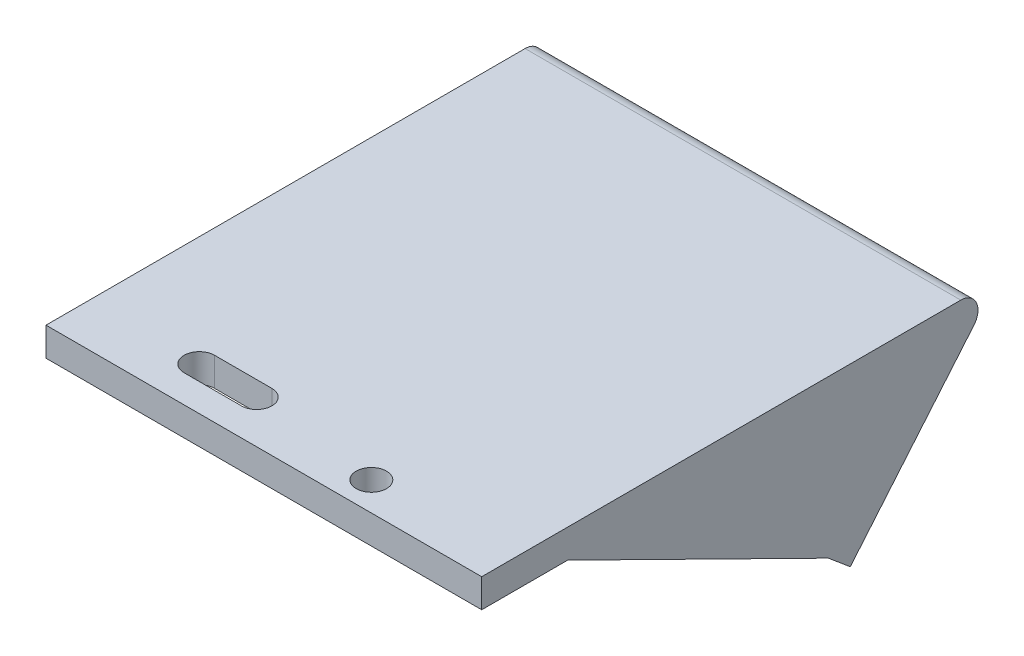
from build123d import *

# Parameters (mm, degrees)
EXTRUDE_1_DEPTH     = 70
SKETCH_2_R          = 1.65
CUT_EXTRUDE_1_DEPTH = 25.69615506
FILLET_1_R          = 3
SKETCH_6_R          = 2.65
CUT_EXTRUDE_4_DEPTH = 31.641777725
EXTRUDE_2_DEPTH     = 3
CUT_EXTRUDE_5_DEPTH = 31.641777725


with BuildPart() as part:
    # 草图1 → 凸台-拉伸1 (new body)
    with BuildSketch(Plane(origin=(0, 0, 0), x_dir=(0, 0, -1), z_dir=(1, 0, 0))):
        Polygon((0, 0), (90, 0), (64.288495613, -30.641777725), (60.458273397, -27.427839676), (79.277465397, -5), (0, -5), align=None)
    extrude(amount=EXTRUDE_1_DEPTH)

    # 草图2 → 切除-拉伸1 (cut, through all)
    with BuildSketch(Plane(origin=(0, -41.102410837, -48.983945779), x_dir=(1, 0, 0), z_dir=(0, 0.64278761, 0.766044443))):
        with Locations((12.5, 27.850884872)):
            Circle(SKETCH_2_R)
        with Locations((57.5, 27.850884872)):
            Circle(SKETCH_2_R)
    extrude(amount=-CUT_EXTRUDE_1_DEPTH, mode=Mode.SUBTRACT)

    # 圆角1
    fillet_1_edges = [part.edges().sort_by_distance(p)[0] for p in [
        (35, 0, -90),
        (35, -5, -79.277465397),
    ]]
    fillet(fillet_1_edges, radius=FILLET_1_R)

    # 草图6 → 切除-拉伸4 (cut, through all)
    with BuildSketch(Plane(origin=(0, 0, 0), x_dir=(1, 0, 0), z_dir=(0, 1, 0))):
        with Locations((48.75, 5)):
            Circle(SKETCH_6_R)
    extrude(amount=-CUT_EXTRUDE_4_DEPTH, mode=Mode.SUBTRACT)

    # 草图7 → 凸台-拉伸2 (add)
    with BuildSketch(Plane.ZY):
        with BuildLine():
            Line((-60.458273397, -27.427839676), (-15, -5))
            Line((-15, -5), (0, -5))
            Line((0, -5), (0, 0))
            Line((0, 0), (-83.566479238, 0))
            ThreePointArc((-83.566479238, 0), (-86.2854026, -1.732145215), (-85.864612568, -4.928362829))
            Line((-85.864612568, -4.928362829), (-64.288495613, -30.641777725))
            Line((-64.288495613, -30.641777725), (-60.458273397, -27.427839676))
        make_face()
    extrude_2 = extrude(amount=EXTRUDE_2_DEPTH)

    # 镜向1: 凸台-拉伸2 across plane
    add(extrude_2.mirror(Plane.ZY.offset(-35)))

    # 草图8 → 切除-拉伸5 (cut, through all)
    with BuildSketch(Plane(origin=(0, 0, 0), x_dir=(1, 0, 0), z_dir=(0, 1, 0))):
        with BuildLine():
            Line((16.25, 10.15), (26.25, 10.15))
            ThreePointArc((26.25, 10.15), (28.9, 7.5), (26.25, 4.85))
            Line((26.25, 4.85), (16.25, 4.85))
            ThreePointArc((16.25, 4.85), (13.6, 7.5), (16.25, 10.15))
        make_face()
    extrude(amount=-CUT_EXTRUDE_5_DEPTH, mode=Mode.SUBTRACT)


solid = part.part
